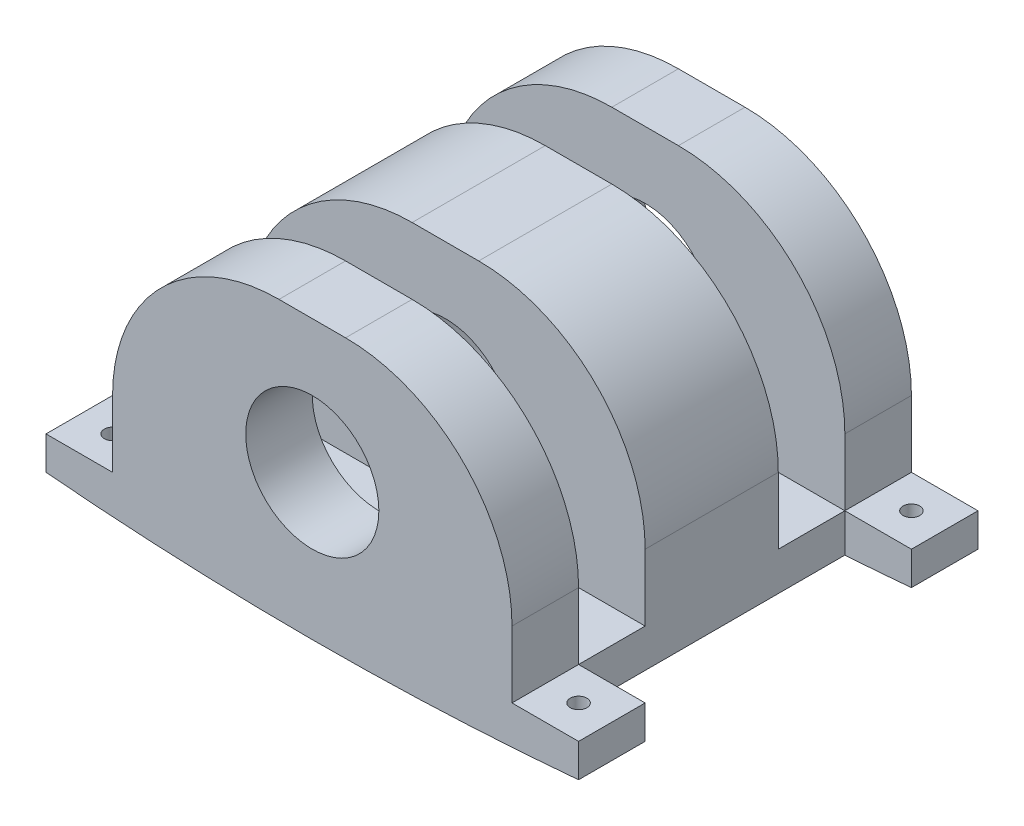
from build123d import *

# Parameters (mm, degrees)
SKETCH1_R                   = 25.4
BOSS_EXTRUDE1_DEPTH         = 152.4
SKETCH3_W                   = 25.4
SKETCH3_H                   = 88.9
CUT_EXTRUDE1_DEPTH          = 102.6
CUT_EXTRUDE1_DEPTH_BACK     = 102.6
F_1_4_0_25_DIAMETER_HOLE1_D = 6.35
SKETCH4_W                   = 25.4
SKETCH4_H                   = 101.6
CUT_EXTRUDE2_DEPTH          = 18.196861737


with BuildPart() as part:
    # Sketch1 → Boss-Extrude1 (new body)
    with BuildSketch(Plane.XY):
        with BuildLine():
            Line((-76.2, -38.1), (-76.2, -12.7))
            ThreePointArc((-76.2, -12.7), (-57.601280605, 32.201280605), (-12.7, 50.8))
            Line((-12.7, 50.8), (12.7, 50.8))
            ThreePointArc((12.7, 50.8), (57.601280605, 32.201280605), (76.2, -12.7))
            Line((76.2, -12.7), (76.2, -38.1))
            Line((76.2, -38.1), (101.6, -38.1))
            Line((101.6, -38.1), (101.6, -50.8))
            ThreePointArc((101.6, -50.8), (0, -55.296861637), (-101.6, -50.8))
            Line((-101.6, -50.8), (-101.6, -38.1))
            Line((-101.6, -38.1), (-76.2, -38.1))
        make_face()
        Circle(SKETCH1_R, mode=Mode.SUBTRACT)
    extrude(amount=BOSS_EXTRUDE1_DEPTH)

    # Sketch3 → Cut-Extrude1 (cut, two sides)
    with BuildSketch(Plane(origin=(0, 0, 0), x_dir=(0, 0, -1), z_dir=(1, 0, 0))) as cut_extrude1_sk:
        with Locations((-114.3, 6.35)):
            Rectangle(SKETCH3_W, SKETCH3_H)
        with Locations((-38.1, 6.35)):
            Rectangle(SKETCH3_W, SKETCH3_H)
    extrude(amount=CUT_EXTRUDE1_DEPTH, mode=Mode.SUBTRACT)
    extrude(cut_extrude1_sk.sketch, amount=-CUT_EXTRUDE1_DEPTH_BACK, mode=Mode.SUBTRACT)

    # 1/4 (0.25) Diameter Hole1 (through all)
    with Locations(Plane(origin=(0, -38.1, 0), x_dir=(1, 0, 0), z_dir=(0, 1, 0))):
        with Locations((-88.9, -12.7), (-88.9, -139.7), (88.9, -12.7), (88.9, -139.7)):
            Hole(F_1_4_0_25_DIAMETER_HOLE1_D / 2)

    # Sketch4 → Cut-Extrude2 (cut, through all)
    with BuildSketch(Plane(origin=(0, -38.1, 0), x_dir=(1, 0, 0), z_dir=(0, 1, 0))):
        with Locations((-88.9, -76.2)):
            Rectangle(SKETCH4_W, SKETCH4_H)
        with Locations((88.9, -76.2)):
            Rectangle(SKETCH4_W, SKETCH4_H)
    extrude(amount=-CUT_EXTRUDE2_DEPTH, mode=Mode.SUBTRACT)


solid = part.part
